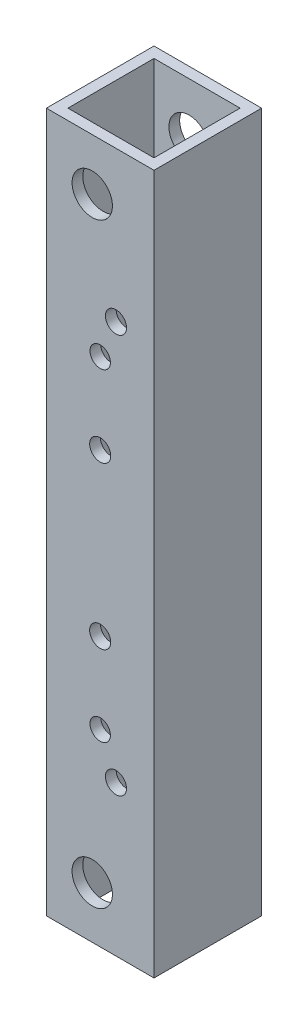
from build123d import *

# Parameters (mm, degrees)
SKETCH1_W           = 25.4
SKETCH1_H           = 165.1
BOSS_EXTRUDE1_DEPTH = 25.4
SKETCH2_W           = 20.32
SKETCH2_H           = 20.32
CUT_EXTRUDE1_DEPTH  = 166.1
SKETCH4_R           = 4.7625
CUT_EXTRUDE2_DEPTH  = 26.4
SKETCH8_R           = 2.4892
SKETCH8_R_2         = 2.413
CUT_EXTRUDE4_DEPTH  = 26.4


with BuildPart() as part:
    # Sketch1 → Boss-Extrude1 (new body)
    with BuildSketch(Plane.XY):
        with Locations((12.7, 82.55)):
            Rectangle(SKETCH1_W, SKETCH1_H)
    extrude(amount=BOSS_EXTRUDE1_DEPTH)

    # Sketch2 → Cut-Extrude1 (cut, through all)
    with BuildSketch(Plane(origin=(0, 165.1, 0), x_dir=(1, 0, 0), z_dir=(0, 1, 0))):
        with Locations((12.7, -12.7)):
            Rectangle(SKETCH2_W, SKETCH2_H)
    extrude(amount=-CUT_EXTRUDE1_DEPTH, mode=Mode.SUBTRACT)

    # Sketch4 → Cut-Extrude2 (cut, through all)
    with BuildSketch(Plane.XY.offset(25.4)):
        with Locations((10.82039492, 152.91000025)):
            Circle(SKETCH4_R)
    cut_extrude2 = extrude(amount=-CUT_EXTRUDE2_DEPTH, mode=Mode.SUBTRACT)

    # Mirror1: Cut-Extrude2 across plane
    add(cut_extrude2.mirror(Plane.ZX.offset(82.55)), mode=Mode.SUBTRACT)

    # Sketch8 → Cut-Extrude4 (cut, through all)
    with BuildSketch(Plane.XY.offset(25.4)):
        with Locations((12.7, 63.5)):
            Circle(SKETCH8_R)
        with Locations((12.7, 44.45)):
            Circle(SKETCH8_R_2)
        with Locations((16.419743879, 35.469743879)):
            Circle(SKETCH8_R)
        with Locations((12.7, 101.6)):
            Circle(SKETCH8_R)
        with Locations((12.7, 120.65)):
            Circle(SKETCH8_R_2)
        with Locations((16.419743879, 129.630256121)):
            Circle(SKETCH8_R)
    extrude(amount=-CUT_EXTRUDE4_DEPTH, mode=Mode.SUBTRACT)


solid = part.part
